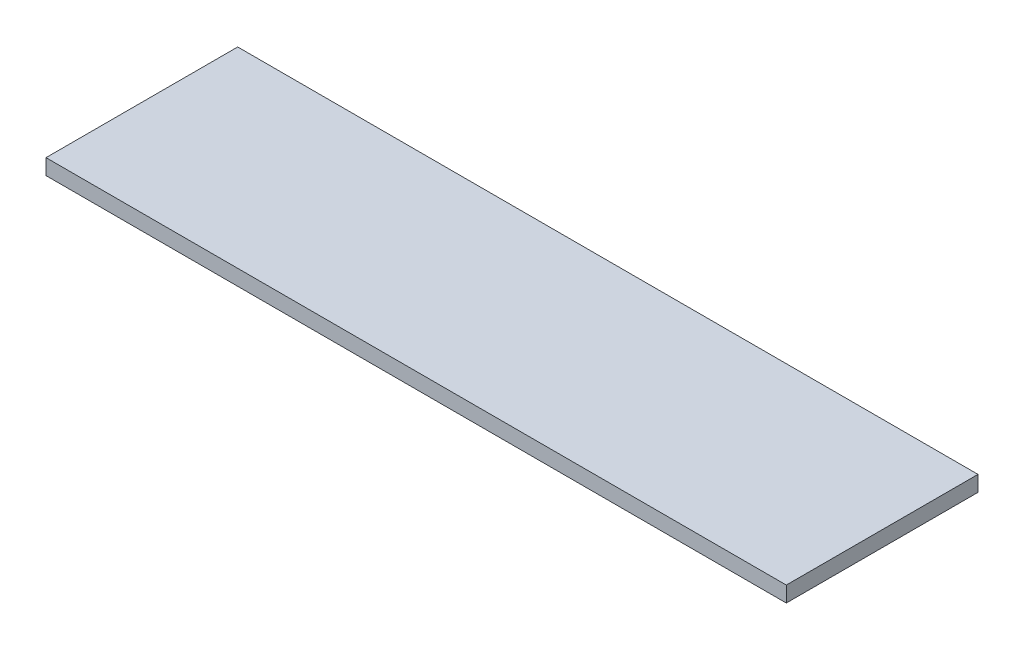
from build123d import *

# Parameters (mm, degrees)
SKETCH1_W           = 47.5
SKETCH1_H           = 12.3
BOSS_EXTRUDE1_DEPTH = 1


with BuildPart() as part:
    # Sketch1 → Boss-Extrude1 (new body)
    with BuildSketch(Plane(origin=(0, 0, 0), x_dir=(1, 0, 0), z_dir=(0, 1, 0))):
        with Locations((23.75, 6.15)):
            Rectangle(SKETCH1_W, SKETCH1_H)
    extrude(amount=BOSS_EXTRUDE1_DEPTH)


solid = part.part
